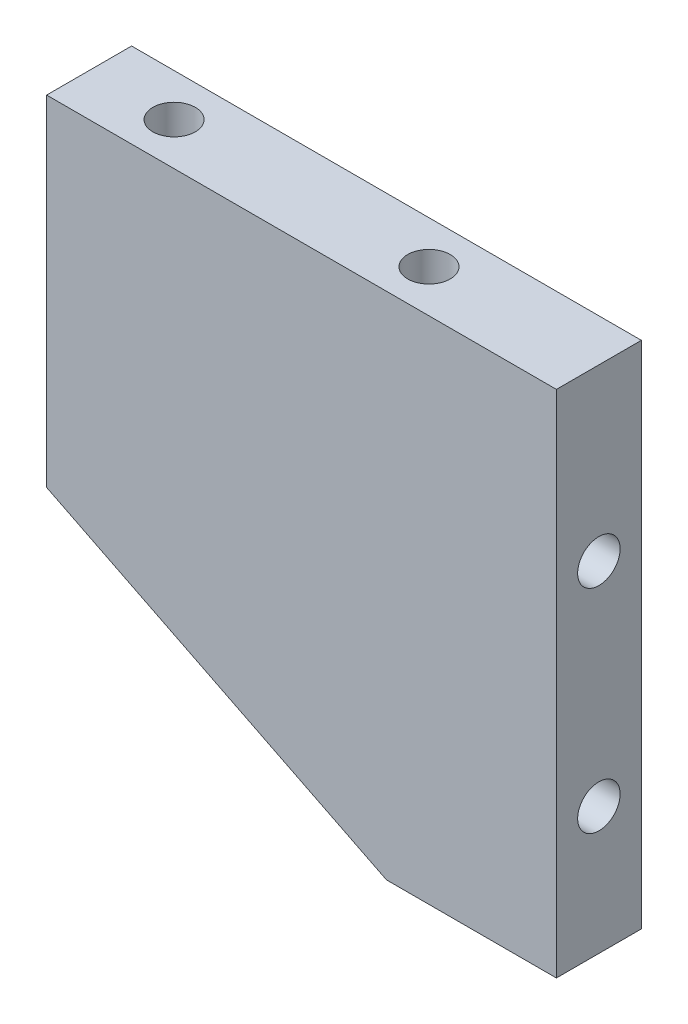
from build123d import *

# Parameters (mm, degrees)
EXTRUDE_1_DEPTH        = 5
HOLE_WIZARD_M6_1_D     = 5
HOLE_WIZARD_M6_1_DEPTH = 15
HOLE_WIZARD_M6_1_TIP   = 1.502151548
HOLE_WIZARD_M6_2_D     = 5
HOLE_WIZARD_M6_2_DEPTH = 15
HOLE_WIZARD_M6_2_TIP   = 1.502151548


with BuildPart() as part:
    # 草图1 → 凸台-拉伸1 (new body, symmetric)
    with BuildSketch(Plane.XY):
        Polygon((0, 0), (-60, 0), (-60, -40), (-20, -60), (0, -60), align=None)
    extrude(amount=EXTRUDE_1_DEPTH, both=True)

    # M6 螺纹孔1
    with Locations(Plane(origin=(0, -20, 0), x_dir=(0, 0, 1), z_dir=(1, 0, 0))):
        with Locations((0, 0), (0, 25)):
            Hole(HOLE_WIZARD_M6_1_D / 2, depth=HOLE_WIZARD_M6_1_DEPTH)
            with Locations((0, 0, -(HOLE_WIZARD_M6_1_DEPTH + HOLE_WIZARD_M6_1_TIP / 2))):  # 118° drill point
                Cone(0, HOLE_WIZARD_M6_1_D / 2, HOLE_WIZARD_M6_1_TIP, mode=Mode.SUBTRACT)

    # M6 螺纹孔2
    with Locations(Plane(origin=(-20, 0, 0), x_dir=(1, 0, 0), z_dir=(0, 1, 0))):
        with Locations((0, 0), (-30, 0)):
            Hole(HOLE_WIZARD_M6_2_D / 2, depth=HOLE_WIZARD_M6_2_DEPTH)
            with Locations((0, 0, -(HOLE_WIZARD_M6_2_DEPTH + HOLE_WIZARD_M6_2_TIP / 2))):  # 118° drill point
                Cone(0, HOLE_WIZARD_M6_2_D / 2, HOLE_WIZARD_M6_2_TIP, mode=Mode.SUBTRACT)


solid = part.part
